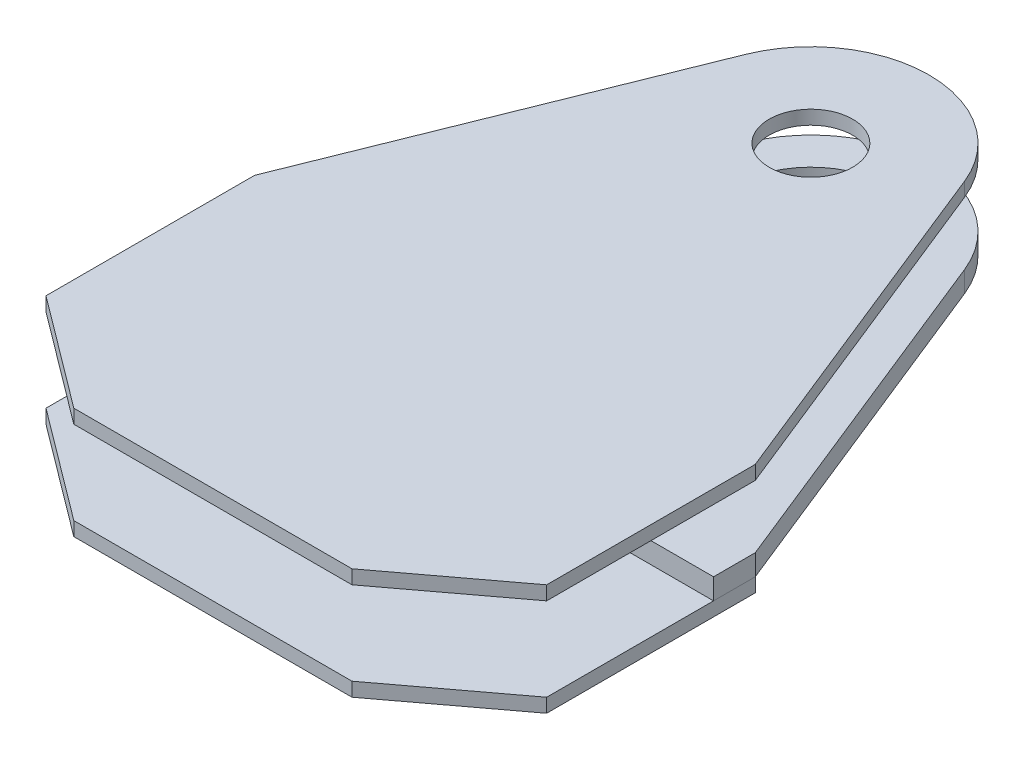
from build123d import *

# Parameters (mm, degrees)
SKETCH3_R           = 36
BOSS_EXTRUDE1_DEPTH = 9.525
SKETCH5_R           = 19.05
BOSS_EXTRUDE2_DEPTH = 6.35
BOSS_EXTRUDE5_DEPTH = 6.35
SKETCH10_R          = 39.175
SKETCH10_R_2        = 32.825
BOSS_EXTRUDE6_DEPTH = 3.175


with BuildPart() as part:
    # Sketch3 → Boss-Extrude1 (new body)
    with BuildSketch(Plane(origin=(0, -19.05, 0), x_dir=(1, 0, 0), z_dir=(0, 1, 0))):
        with BuildLine():
            Line((50.083433466, 20.123377381), (114.3, -139.7))
            Line((114.3, -139.7), (114.3, -158.75))
            Line((114.3, -158.75), (25.4, -158.75))
            Line((25.4, -158.75), (25.4, -183.759139639))
            ThreePointArc((25.4, -183.759139639), (0, -168.275), (-25.4, -183.759139639))
            Line((-25.4, -183.759139639), (-25.4, -158.75))
            Line((-25.4, -158.75), (-114.3, -158.75))
            Line((-114.3, -158.75), (-114.3, -139.7))
            Line((-114.3, -139.7), (-50.083433466, 20.123377381))
            ThreePointArc((-50.083433466, 20.123377381), (-30.225331519, 44.718340304), (0, 53.975))
            ThreePointArc((0, 53.975), (30.225331519, 44.718340304), (50.083433466, 20.123377381))
        make_face()
        Circle(SKETCH3_R, mode=Mode.SUBTRACT)
    extrude(amount=BOSS_EXTRUDE1_DEPTH)


with BuildPart() as body_2:
    # Sketch5 → Boss-Extrude2 (new body)
    with BuildSketch(Plane(origin=(0, 19.05, 0), x_dir=(1, 0, 0), z_dir=(0, 1, 0))):
        with BuildLine():
            Line((-114.3, -158.75), (-114.3, -234.95))
            Line((-114.3, -234.95), (-63.5, -273.05))
            Line((-63.5, -273.05), (63.5, -273.05))
            Line((63.5, -273.05), (114.3, -234.95))
            Line((114.3, -234.95), (114.3, -158.75))
            Line((114.3, -158.75), (114.3, -139.7))
            Line((114.3, -139.7), (50.083433466, 20.123377381))
            ThreePointArc((50.083433466, 20.123377381), (0, 53.975), (-50.083433466, 20.123377381))
            Line((-50.083433466, 20.123377381), (-114.3, -139.7))
            Line((-114.3, -139.7), (-114.3, -158.75))
        make_face()
        Circle(SKETCH5_R, mode=Mode.SUBTRACT)
    extrude(amount=BOSS_EXTRUDE2_DEPTH)


with BuildPart() as body_3:
    # Sketch9 → Boss-Extrude5 (new body)
    with BuildSketch(Plane.XZ.offset(19.05)):
        with BuildLine():
            Line((-114.3, 139.7), (-114.3, 234.95))
            Line((-114.3, 234.95), (-63.5, 273.05))
            Line((-63.5, 273.05), (63.5, 273.05))
            Line((63.5, 273.05), (114.3, 234.95))
            Line((114.3, 234.95), (114.3, 139.7))
            Line((114.3, 139.7), (93.810370562, 139.7))
            ThreePointArc((93.810370562, 139.7), (0, 168.275), (-93.810370562, 139.7))
            Line((-93.810370562, 139.7), (-114.3, 139.7))
        make_face()
    extrude(amount=BOSS_EXTRUDE5_DEPTH)


with BuildPart() as body_4:
    # Sketch10 → Boss-Extrude6 (new body)
    with BuildSketch(Plane.XZ.offset(19.05)):
        Circle(SKETCH10_R)
        Circle(SKETCH10_R_2, mode=Mode.SUBTRACT)
    extrude(amount=BOSS_EXTRUDE6_DEPTH)


solid = Compound([part.part, body_2.part, body_3.part, body_4.part])
